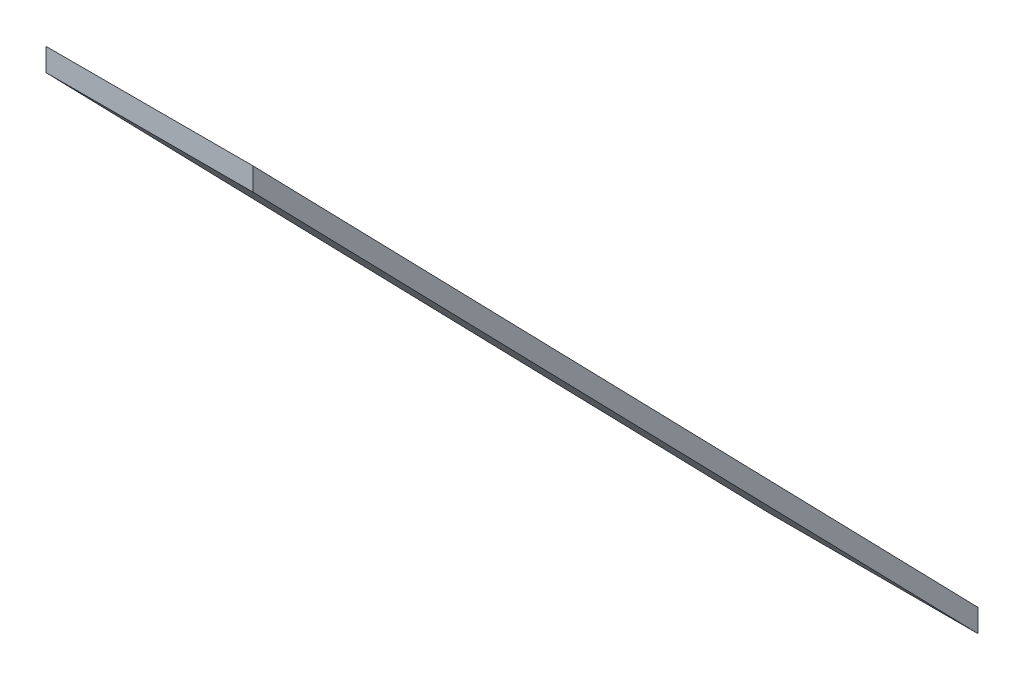
from build123d import *

# Parameters (mm, degrees)
SKETCH9_W = 1000
SKETCH9_H = 110


with BuildPart() as part:
    # Sweep3: sweep along a path in Sketch7
    with BuildLine(Plane(origin=(0, 0, 0), x_dir=(0, 0, -1), z_dir=(1, 0, 0))) as sweep3_path:
        Line((-3500, 3541), (0, -55))
    # Sketch9 → Sweep3 (sweep)
    with BuildSketch(Plane.XY.offset(3500)):
        with Locations((0, 3596)):
            Rectangle(SKETCH9_W, SKETCH9_H)
    sweep(path=sweep3_path.line)


solid = part.part
